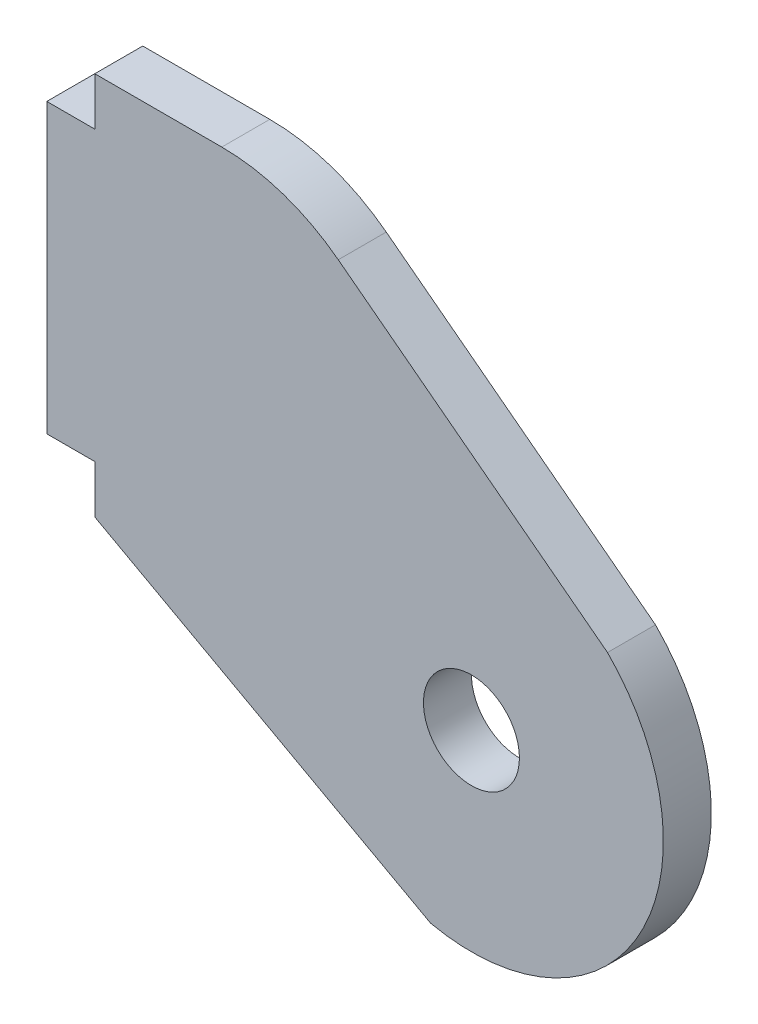
from build123d import *

# Parameters (mm, degrees)
BOSS_EXTRUDE1_DEPTH             = 3.175
F_1_4_0_25_DIAMETER_HOLE1_D     = 6.35
F_1_4_0_25_DIAMETER_HOLE1_DEPTH = 9.268267535
F_1_4_0_25_DIAMETER_HOLE1_TIP   = 1.907732465
FILLET1_R                       = 12.7


with BuildPart() as part:
    # Sketch1 → Boss-Extrude1 (new body)
    with BuildSketch(Plane.XY):
        with BuildLine():
            Line((427.919423357, 0), (440.619423357, 0))
            Line((440.619423357, 0), (461.846041333, -16.2036647))
            ThreePointArc((461.846041333, -16.2036647), (463.98221908, -31.261387982), (450.144423357, -37.571197432))
            Line((450.144423357, -37.571197432), (427.919423357, -25.4))
            Line((427.919423357, -25.4), (427.919423357, -22.225))
            Line((427.919423357, -22.225), (424.744423357, -22.225))
            Line((424.744423357, -22.225), (424.744423357, -3.175))
            Line((424.744423357, -3.175), (427.919423357, -3.175))
            Line((427.919423357, -3.175), (427.919423357, 0))
        make_face()
    extrude(amount=BOSS_EXTRUDE1_DEPTH)

    # 1/4 (0.25) Diameter Hole1
    with Locations(Plane.XY.offset(3.175)):
        with Locations((452.843173357, -25.161251887)):
            Hole(F_1_4_0_25_DIAMETER_HOLE1_D / 2, depth=F_1_4_0_25_DIAMETER_HOLE1_DEPTH)
            with Locations((0, 0, -(F_1_4_0_25_DIAMETER_HOLE1_DEPTH + F_1_4_0_25_DIAMETER_HOLE1_TIP / 2))):  # 118° drill point
                Cone(0, F_1_4_0_25_DIAMETER_HOLE1_D / 2, F_1_4_0_25_DIAMETER_HOLE1_TIP, mode=Mode.SUBTRACT)

    # Fillet1
    fillet1_edges = [part.edges().sort_by_distance(p)[0] for p in [
        (440.619423357, 0, 1.5875),
    ]]
    fillet(fillet1_edges, radius=FILLET1_R)


solid = part.part
